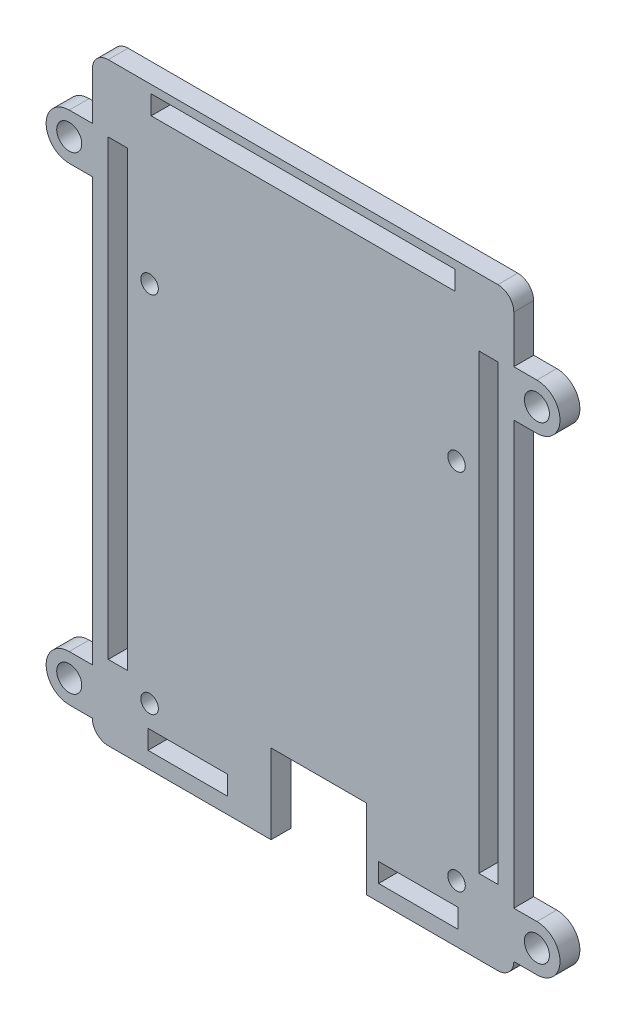
from build123d import *

# Parameters (mm, degrees)
SKETCH1_W           = 12.7
SKETCH1_H           = 3.048
SKETCH1_R           = 1.397
SKETCH1_W_2         = 48.514
SKETCH1_H_2         = 1.8034
BOSS_EXTRUDE1_DEPTH = 3.175
SKETCH6_W           = 48.514
SKETCH6_H           = 3.048
CUT_EXTRUDE2_DEPTH  = 4.175
SKETCH5_R           = 3.6891
SKETCH5_R_2         = 2
BOSS_EXTRUDE3_DEPTH = 3.175


with BuildPart() as part:
    # Sketch1 → Boss-Extrude1 (new body)
    with BuildSketch(Plane.XY):
        with BuildLine():
            Line((38.227, 7.112), (38.227, 0))
            Line((38.227, 0), (38.227, -5.588))
            Line((38.227, -5.588), (59.182, -5.588))
            ThreePointArc((59.182, -5.588), (60.978051224, -4.844051224), (61.722, -3.048))
            Line((61.722, -3.048), (61.722, 86.7664))
            ThreePointArc((61.722, 86.7664), (60.978051224, 88.562451224), (59.182, 89.3064))
            Line((59.182, 89.3064), (-3.048, 89.3064))
            ThreePointArc((-3.048, 89.3064), (-4.844051224, 88.562451224), (-5.588, 86.7664))
            Line((-5.588, 86.7664), (-5.588, -3.048))
            ThreePointArc((-5.588, -3.048), (-4.844051224, -4.844051224), (-3.048, -5.588))
            Line((-3.048, -5.588), (22.9616, -5.588))
            Line((22.9616, -5.588), (22.9616, 0))
            Line((22.9616, 0), (22.9616, 7.112))
            Line((22.9616, 7.112), (38.227, 7.112))
        make_face()
        with Locations((9.652, -1.524)):
            Rectangle(SKETCH1_W, SKETCH1_H, mode=Mode.SUBTRACT)
        with Locations((3.556, 3.556)):
            Circle(SKETCH1_R, mode=Mode.SUBTRACT)
        with Locations((46.482, -1.524)):
            Rectangle(SKETCH1_W, SKETCH1_H, mode=Mode.SUBTRACT)
        with Locations((52.578, 3.556)):
            Circle(SKETCH1_R, mode=Mode.SUBTRACT)
        Polygon((-3.048, 6.35), (-3.048, 78.613), (0, 78.613), (0, 61.595), (0, 6.35), align=None, mode=Mode.SUBTRACT)
        with Locations((3.556, 61.595)):
            Circle(SKETCH1_R, mode=Mode.SUBTRACT)
        with Locations((28.067, 85.8647)):
            Rectangle(SKETCH1_W_2, SKETCH1_H_2, mode=Mode.SUBTRACT)
        Polygon((56.134, 78.613), (59.182, 78.613), (59.182, 6.35), (56.134, 6.35), (56.134, 61.595), align=None, mode=Mode.SUBTRACT)
        with Locations((52.578, 61.595)):
            Circle(SKETCH1_R, mode=Mode.SUBTRACT)
    extrude(amount=BOSS_EXTRUDE1_DEPTH)

    # Sketch6 → Cut-Extrude2 (cut, through all)
    with BuildSketch(Plane.XY.offset(3.175)):
        with Locations((28.067, 86.487)):
            Rectangle(SKETCH6_W, SKETCH6_H)
    extrude(amount=-CUT_EXTRUDE2_DEPTH, mode=Mode.SUBTRACT)

    # Sketch5 → Boss-Extrude3 (add)
    with BuildSketch(Plane.XY.offset(3.175)):
        with BuildLine():
            Line((-5.588, 4.3302), (-9.2771, 4.3302))
            ThreePointArc((-9.2771, 4.3302), (-6.668512374, 3.249687626), (-5.588, 0.6411))
            Line((-5.588, 0.6411), (-5.588, 4.3302))
        make_face()
        with BuildLine():
            Line((-5.588, -3.048), (-5.588, 0.6411))
            ThreePointArc((-5.588, 0.6411), (-6.668512374, -1.967487626), (-9.2771, -3.048))
            Line((-9.2771, -3.048), (-5.588, -3.048))
        make_face()
        with Locations((-9.2771, 0.6411)):
            Circle(SKETCH5_R)
        with Locations((-9.2771, 0.6411)):
            Circle(SKETCH5_R_2, mode=Mode.SUBTRACT)
        with Locations((65.4111, 0.6411)):
            Circle(SKETCH5_R)
        with Locations((65.4111, 0.6411)):
            Circle(SKETCH5_R_2, mode=Mode.SUBTRACT)
        with BuildLine():
            Line((61.722, -3.048), (65.4111, -3.048))
            ThreePointArc((65.4111, -3.048), (62.802512374, -1.967487626), (61.722, 0.6411))
            Line((61.722, 0.6411), (61.722, -3.048))
        make_face()
        with BuildLine():
            Line((61.722, 4.3302), (61.722, 0.6411))
            ThreePointArc((61.722, 0.6411), (62.802512374, 3.249687626), (65.4111, 4.3302))
            Line((65.4111, 4.3302), (61.722, 4.3302))
        make_face()
        with Locations((65.4111, 75.5325)):
            Circle(SKETCH5_R)
        with Locations((65.4111, 75.5325)):
            Circle(SKETCH5_R_2, mode=Mode.SUBTRACT)
        with BuildLine():
            Line((61.722, 71.8434), (65.4111, 71.8434))
            ThreePointArc((65.4111, 71.8434), (62.802512374, 72.923912374), (61.722, 75.5325))
            Line((61.722, 75.5325), (61.722, 71.8434))
        make_face()
        with BuildLine():
            Line((61.722, 79.2216), (61.722, 75.5325))
            ThreePointArc((61.722, 75.5325), (62.802512374, 78.141087626), (65.4111, 79.2216))
            Line((65.4111, 79.2216), (61.722, 79.2216))
        make_face()
        with BuildLine():
            Line((-5.588, 71.8434), (-5.588, 75.5325))
            ThreePointArc((-5.588, 75.5325), (-6.668512374, 72.923912374), (-9.2771, 71.8434))
            Line((-9.2771, 71.8434), (-5.588, 71.8434))
        make_face()
        with Locations((-9.2771, 75.5325)):
            Circle(SKETCH5_R)
        with Locations((-9.2771, 75.5325)):
            Circle(SKETCH5_R_2, mode=Mode.SUBTRACT)
        with BuildLine():
            Line((-5.588, 79.2216), (-9.2771, 79.2216))
            ThreePointArc((-9.2771, 79.2216), (-6.668512374, 78.141087626), (-5.588, 75.5325))
            Line((-5.588, 75.5325), (-5.588, 79.2216))
        make_face()
    extrude(amount=-BOSS_EXTRUDE3_DEPTH)


solid = part.part
